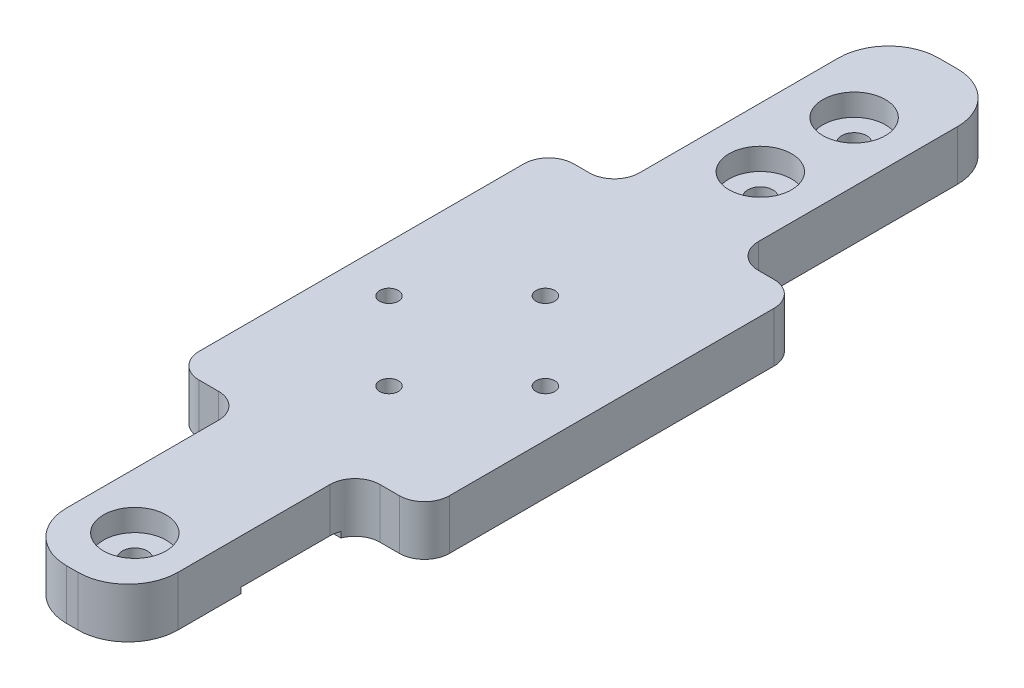
from build123d import *

# Parameters (mm, degrees)
SKETCH1_W               = 40
SKETCH1_H               = 140
BOSS_EXTRUDE1_DEPTH     = 8
SKETCH2_W               = 10.491495072
SKETCH2_H               = 43.818703547
SKETCH2_W_2             = 11.094869632
SKETCH2_H_2             = 36.296784829
CUT_EXTRUDE1_DEPTH      = 1
CUT_EXTRUDE1_DEPTH_BACK = 9
FILLET3_R               = 8
FILLET4_R               = 4
SKETCH3_R               = 1.5
CUT_EXTRUDE2_DEPTH      = 1
CUT_EXTRUDE2_DEPTH_BACK = 9
SKETCH4_W               = 15.7
SKETCH4_H               = 0.9
CUT_EXTRUDE3_DEPTH      = 12.094869632
CUT_EXTRUDE3_DEPTH_BACK = 29.905130368
SKETCH5_R               = 3.05
CUT_EXTRUDE4_DEPTH      = 5.5
SKETCH6_R               = 2
CUT_EXTRUDE5_DEPTH      = 1
CUT_EXTRUDE5_DEPTH_BACK = 9
SKETCH7_R               = 5
CUT_EXTRUDE6_DEPTH      = 3.5


with BuildPart() as part:
    # Sketch1 → Boss-Extrude1 (new body)
    with BuildSketch(Plane(origin=(0, 0, 0), x_dir=(1, 0, 0), z_dir=(0, 1, 0))):
        Rectangle(SKETCH1_W, SKETCH1_H)
    extrude(amount=BOSS_EXTRUDE1_DEPTH)

    # Sketch2 → Cut-Extrude1 (cut, two sides)
    with BuildSketch(Plane(origin=(0, 8, 0), x_dir=(1, 0, 0), z_dir=(0, 1, 0))) as cut_extrude1_sk:
        with Locations((14.754252464, 48.090648227)):
            Rectangle(SKETCH2_W, SKETCH2_H)
        with Locations((-14.452565184, -51.851607586)):
            Rectangle(SKETCH2_W_2, SKETCH2_H_2)
        with Locations((14.452565184, -51.851607586)):
            Rectangle(SKETCH2_W_2, SKETCH2_H_2)
        with Locations((-14.754252464, 48.090648227)):
            Rectangle(SKETCH2_W, SKETCH2_H)
    extrude(amount=CUT_EXTRUDE1_DEPTH, mode=Mode.SUBTRACT)
    extrude(cut_extrude1_sk.sketch, amount=-CUT_EXTRUDE1_DEPTH_BACK, mode=Mode.SUBTRACT)

    # Fillet3
    fillet3_edges = [part.edges().sort_by_distance(p)[0] for p in [
        (-9.508504928, 4, -70),
        (8.905130368, 4, 70),
        (-8.905130368, 4, 70),
        (9.508504928, 4, -70),
    ]]
    fillet(fillet3_edges, radius=FILLET3_R)

    # Fillet4
    fillet4_edges = [part.edges().sort_by_distance(p)[0] for p in [
        (-9.508504928, 4, -26.181296453),
        (-20, 4, -26.181296453),
        (8.905130368, 4, 33.703215171),
        (20, 4, 33.703215171),
        (-8.905130368, 4, 33.703215171),
        (-20, 4, 33.703215171),
        (9.508504928, 4, -26.181296453),
        (20, 4, -26.181296453),
    ]]
    fillet(fillet4_edges, radius=FILLET4_R)

    # Sketch3 → Cut-Extrude2 (cut, two sides)
    with BuildSketch(Plane(origin=(0, 8, 0), x_dir=(1, 0, 0), z_dir=(0, 1, 0))) as cut_extrude2_sk:
        with Locations((12.5, -6.862591123)):
            Circle(SKETCH3_R)
        with Locations((0, 5.637408877)):
            Circle(SKETCH3_R)
        with Locations((-12.5, -6.862591123)):
            Circle(SKETCH3_R)
        with Locations((0, -19.362591123)):
            Circle(SKETCH3_R)
    extrude(amount=CUT_EXTRUDE2_DEPTH, mode=Mode.SUBTRACT)
    extrude(cut_extrude2_sk.sketch, amount=-CUT_EXTRUDE2_DEPTH_BACK, mode=Mode.SUBTRACT)

    # Sketch4 → Cut-Extrude3 (cut, two sides)
    with BuildSketch(Plane(origin=(8.905130368, 0, 0), x_dir=(0, 0, -1), z_dir=(1, 0, 0))) as cut_extrude3_sk:
        with Locations((-44.089134708, 0.45)):
            Rectangle(SKETCH4_W, SKETCH4_H)
    extrude(amount=CUT_EXTRUDE3_DEPTH, mode=Mode.SUBTRACT)
    extrude(cut_extrude3_sk.sketch, amount=-CUT_EXTRUDE3_DEPTH_BACK, mode=Mode.SUBTRACT)

    # Sketch5 → Cut-Extrude4 (cut)
    with BuildSketch(Plane.XZ):
        with Locations((12.5, 6.862591123)):
            Circle(SKETCH5_R)
        with Locations((0, -5.637408877)):
            Circle(SKETCH5_R)
        with Locations((-12.5, 6.862591123)):
            Circle(SKETCH5_R)
        with Locations((0, 19.362591123)):
            Circle(SKETCH5_R)
    extrude(amount=-CUT_EXTRUDE4_DEPTH, mode=Mode.SUBTRACT)

    # Sketch6 → Cut-Extrude5 (cut, two sides)
    with BuildSketch(Plane.XZ) as cut_extrude5_sk:
        with Locations((0, 60)):
            Circle(SKETCH6_R)
        with Locations((0, -55)):
            Circle(SKETCH6_R)
        with Locations((0, -40)):
            Circle(SKETCH6_R)
    extrude(amount=CUT_EXTRUDE5_DEPTH, mode=Mode.SUBTRACT)
    extrude(cut_extrude5_sk.sketch, amount=-CUT_EXTRUDE5_DEPTH_BACK, mode=Mode.SUBTRACT)

    # Sketch7 → Cut-Extrude6 (cut)
    with BuildSketch(Plane(origin=(0, 8, 0), x_dir=(1, 0, 0), z_dir=(0, 1, 0))):
        with Locations((0, 55)):
            Circle(SKETCH7_R)
        with Locations((0, -60)):
            Circle(SKETCH7_R)
        with Locations((0, 40)):
            Circle(SKETCH7_R)
    extrude(amount=-CUT_EXTRUDE6_DEPTH, mode=Mode.SUBTRACT)


solid = part.part
